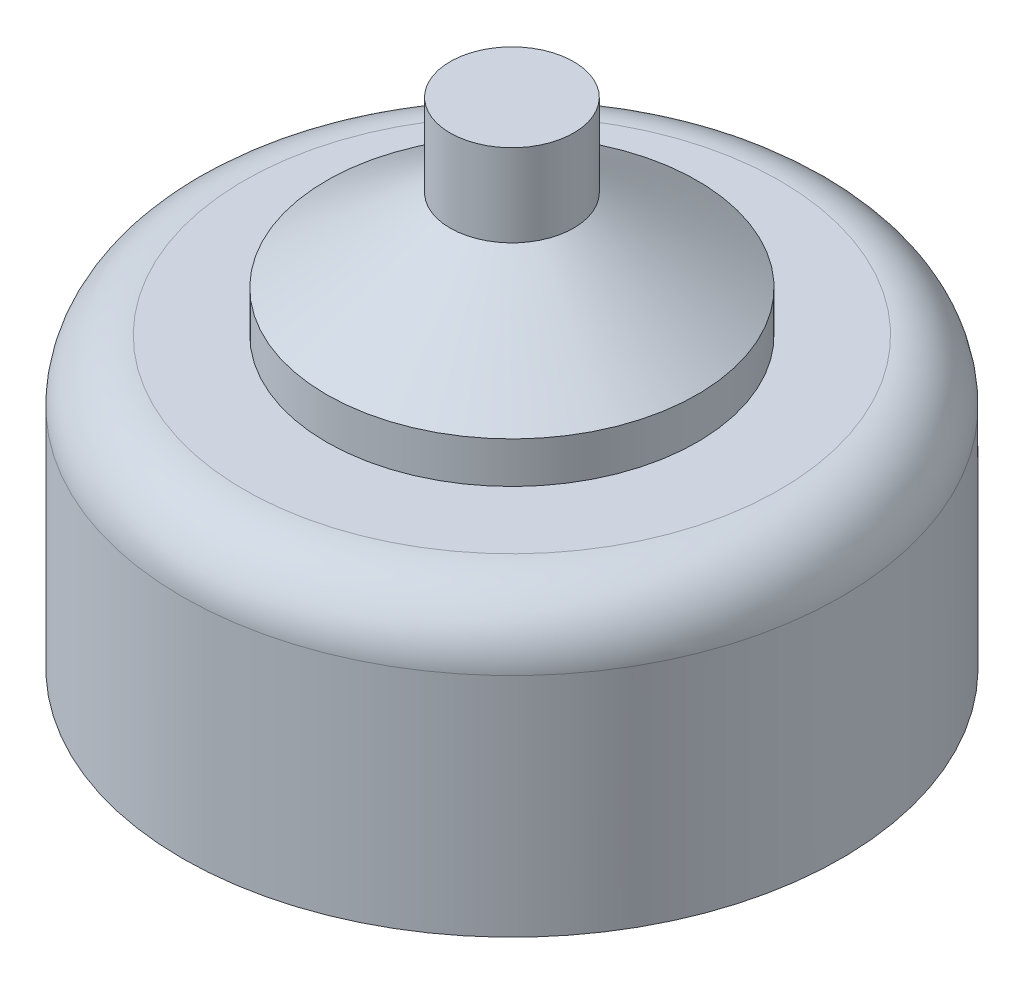
from build123d import *

# Parameters (mm, degrees)
FILLET2_R           = 1.5
SKETCH3_R           = 2
BOSS_EXTRUDE1_DEPTH = 3


with BuildPart() as part:
    # Sketch2 → Revolve1 (revolve)
    with BuildSketch(Plane.XY):
        Polygon((0, -30.015007431), (8, -30.015007431), (8, -23.015007431), (4.5, -23.015007431), (4.5, -22.015007431), (1.5, -20.015007431), (1.5, -18.015007431), (0, -18.015007431), align=None)
    revolve(axis=Axis((0, 46.076216781, 0), (0, -1, 0)))

    # Fillet2
    fillet2_edges = [part.edges().sort_by_distance(p)[0] for p in [
        (-8, -23.015007431, 0),
    ]]
    fillet(fillet2_edges, radius=FILLET2_R)

    # Sketch3 → Boss-Extrude1 (add)
    with BuildSketch(Plane.XZ.offset(30.015007431)):
        Circle(SKETCH3_R)
    extrude(amount=BOSS_EXTRUDE1_DEPTH)


solid = part.part
